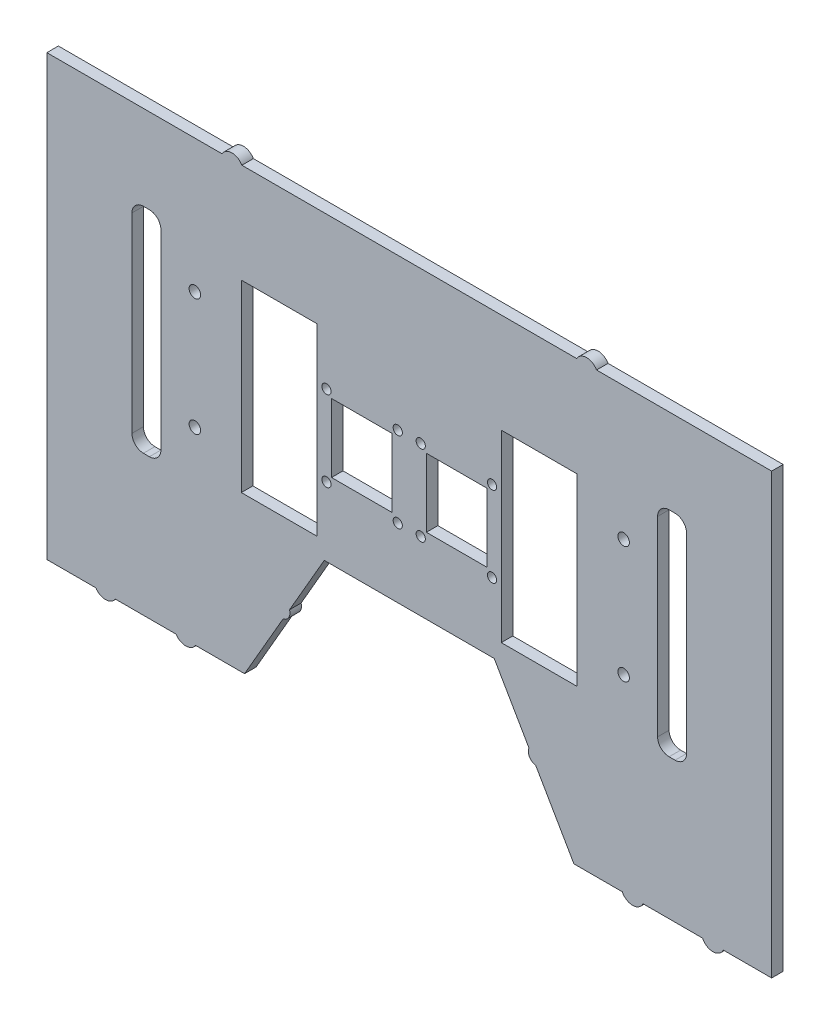
from build123d import *

# Parameters (mm, degrees)
SKETCH1_R           = 2
SKETCH1_R_2         = 2.5
SKETCH1_W           = 33
SKETCH1_H           = 80
SKETCH1_W_2         = 26.358753283
SKETCH1_H_2         = 29.759882739
BOSS_EXTRUDE1_DEPTH = 5


with BuildPart() as part:
    # Sketch1 → Boss-Extrude1 (new body)
    with BuildSketch(Plane.XY):
        with BuildLine():
            Line((-125.940029712, -95.672909388), (-104.635809021, -95.672909388))
            ThreePointArc((-104.635809021, -95.672909388), (-100.405628635, -98.00728115), (-96.175448249, -95.672909388))
            Line((-96.175448249, -95.672909388), (-69.744751877, -95.672909388))
            ThreePointArc((-69.744751877, -95.672909388), (-65.514571491, -98.00728115), (-61.284391105, -95.672909388))
            Line((-61.284391105, -95.672909388), (-39.980170414, -95.672909388))
            Line((-39.980170414, -95.672909388), (-23.23481866, -66.66910936))
            ThreePointArc((-23.23481866, -66.66910936), (-20.75474442, -64.873494769), (-20.439733688, -61.827880177))
            Line((-20.439733688, -61.827880177), (-5.339154263, -35.672909388))
            Line((-5.339154263, -35.672909388), (68.561680194, -35.672909388))
            Line((68.561680194, -35.672909388), (83.651079822, -61.808516201))
            ThreePointArc((83.651079822, -61.808516201), (83.885152959, -65.076529173), (86.598298645, -66.913248943))
            Line((86.598298645, -66.913248943), (103.202696345, -95.672909388))
            Line((103.202696345, -95.672909388), (124.216145364, -95.672909388))
            ThreePointArc((124.216145364, -95.672909388), (128.736262965, -98.535495794), (133.256380567, -95.672909388))
            Line((133.256380567, -95.672909388), (159.108871421, -95.672909388))
            ThreePointArc((159.108871421, -95.672909388), (163.628989022, -98.535495794), (168.149106623, -95.672909388))
            Line((168.149106623, -95.672909388), (189.162555642, -95.672909388))
            Line((189.162555642, -95.672909388), (189.162555642, 95.180535099))
            Line((189.162555642, 95.180535099), (113.042402195, 95.180535099))
            ThreePointArc((113.042402195, 95.180535099), (108.712275177, 97.680535099), (104.382148158, 95.180535099))
            Line((104.382148158, 95.180535099), (-41.159528738, 95.180535099))
            ThreePointArc((-41.159528738, 95.180535099), (-45.489655757, 97.680535099), (-49.819782776, 95.180535099))
            Line((-49.819782776, 95.180535099), (-125.940029712, 95.180535099))
            Line((-125.940029712, 95.180535099), (-125.940029712, -95.672909388))
        make_face()
        with Locations((67.611262965, 29.327090612)):
            Circle(SKETCH1_R, mode=Mode.SUBTRACT)
        with Locations((36.611262965, 29.327090612)):
            Circle(SKETCH1_R, mode=Mode.SUBTRACT)
        with Locations((26.611262965, 29.327090612)):
            Circle(SKETCH1_R, mode=Mode.SUBTRACT)
        with Locations((-4.388737035, 29.327090612)):
            Circle(SKETCH1_R, mode=Mode.SUBTRACT)
        with Locations((67.611262965, -5.672909388)):
            Circle(SKETCH1_R, mode=Mode.SUBTRACT)
        with Locations((36.611262965, -5.672909388)):
            Circle(SKETCH1_R, mode=Mode.SUBTRACT)
        with Locations((26.611262965, -5.672909388)):
            Circle(SKETCH1_R, mode=Mode.SUBTRACT)
        with Locations((-4.388737035, -5.672909388)):
            Circle(SKETCH1_R, mode=Mode.SUBTRACT)
        with Locations((-61.588737035, -13.672909388)):
            Circle(SKETCH1_R_2, mode=Mode.SUBTRACT)
        with Locations((-61.588737035, 37.327090612)):
            Circle(SKETCH1_R_2, mode=Mode.SUBTRACT)
        with Locations((124.811262965, 37.327090612)):
            Circle(SKETCH1_R_2, mode=Mode.SUBTRACT)
        with Locations((124.811262965, -13.672909388)):
            Circle(SKETCH1_R_2, mode=Mode.SUBTRACT)
        with Locations((-24.888737035, 11.827090612)):
            Rectangle(SKETCH1_W, SKETCH1_H, mode=Mode.SUBTRACT)
        with Locations((88.111262965, 11.827090612)):
            Rectangle(SKETCH1_W, SKETCH1_H, mode=Mode.SUBTRACT)
        with BuildLine():
            Line((144.581262965, -34.665729578), (147.181262965, -34.665729578))
            ThreePointArc((147.181262965, -34.665729578), (150.716796871, -33.201263484), (152.181262965, -29.665729578))
            Line((152.181262965, -29.665729578), (152.181262965, 53.319910802))
            ThreePointArc((152.181262965, 53.319910802), (150.716796871, 56.855444707), (147.181262965, 58.319910802))
            Line((147.181262965, 58.319910802), (144.581262965, 58.319910802))
            ThreePointArc((144.581262965, 58.319910802), (141.04572906, 56.855444707), (139.581262965, 53.319910802))
            Line((139.581262965, 53.319910802), (139.581262965, -29.665729578))
            ThreePointArc((139.581262965, -29.665729578), (141.04572906, -33.201263484), (144.581262965, -34.665729578))
        make_face(mode=Mode.SUBTRACT)
        with BuildLine():
            Line((-83.958737035, -34.665729578), (-81.358737035, -34.665729578))
            ThreePointArc((-81.358737035, -34.665729578), (-77.823203129, -33.201263484), (-76.358737035, -29.665729578))
            Line((-76.358737035, -29.665729578), (-76.358737035, 53.319910802))
            ThreePointArc((-76.358737035, 53.319910802), (-77.823203129, 56.855444707), (-81.358737035, 58.319910802))
            Line((-81.358737035, 58.319910802), (-83.958737035, 58.319910802))
            ThreePointArc((-83.958737035, 58.319910802), (-87.49427094, 56.855444707), (-88.958737035, 53.319910802))
            Line((-88.958737035, 53.319910802), (-88.958737035, -29.665729578))
            ThreePointArc((-88.958737035, -29.665729578), (-87.49427094, -33.201263484), (-83.958737035, -34.665729578))
        make_face(mode=Mode.SUBTRACT)
        with Locations((52.23838386, 11.97050865)):
            Rectangle(SKETCH1_W_2, SKETCH1_H_2, mode=Mode.SUBTRACT)
        with Locations((10.98423556, 11.97050865)):
            Rectangle(SKETCH1_W_2, SKETCH1_H_2, mode=Mode.SUBTRACT)
    extrude(amount=BOSS_EXTRUDE1_DEPTH)


solid = part.part
